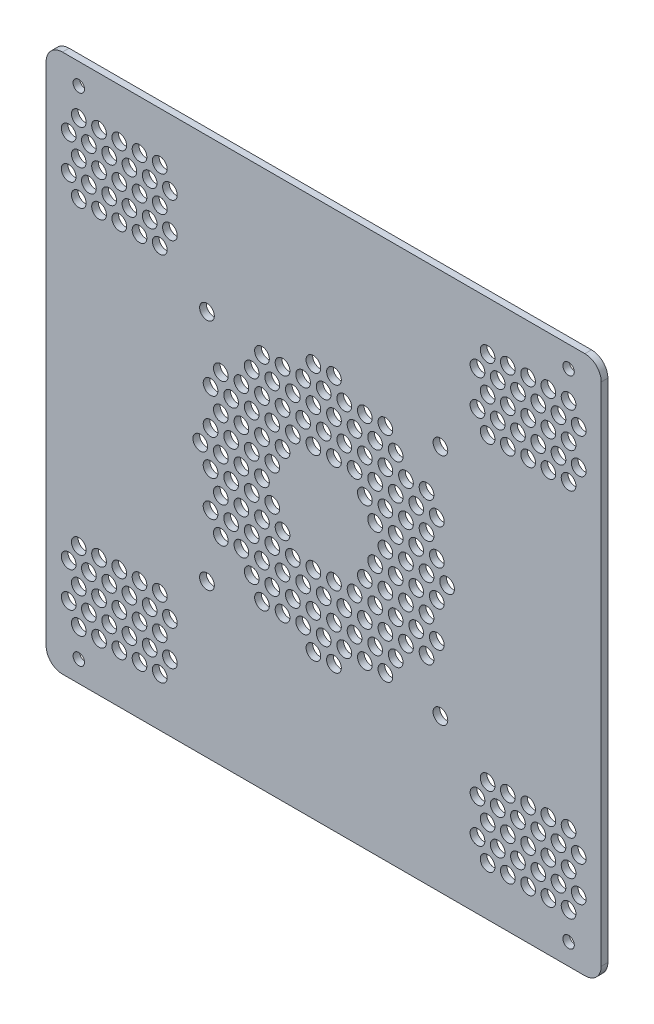
from build123d import *

# Parameters (mm, degrees)
SKETCH1_R            = 1.75
SKETCH1_R_2          = 2.25
BOSS_EXTRUDE1_DEPTH  = 2.032
SKETCH3_R            = 2.25
CUT_EXTRUDE2_DEPTH   = 3.032
LPATTERN1_COUNT      = 2
LPATTERN1_PITCH      = 113.5226
LPATTERN1_COUNT_DIR2 = 2
LPATTERN1_PITCH_DIR2 = 125.2
SKETCH4_R            = 2.25
CUT_EXTRUDE3_DEPTH   = 3.032
CIRPATTERN1_COUNT    = 6


with BuildPart() as part:
    # Sketch1 → Boss-Extrude1 (new body)
    with BuildSketch(Plane.XY):
        with BuildLine():
            Line((-80, 82.5), (80, 82.5))
            ThreePointArc((80, 82.5), (83.535533906, 81.035533906), (85, 77.5))
            Line((85, 77.5), (85, -77.5))
            ThreePointArc((85, -77.5), (83.535533906, -81.035533906), (80, -82.5))
            Line((80, -82.5), (-80, -82.5))
            ThreePointArc((-80, -82.5), (-83.535533906, -81.035533906), (-85, -77.5))
            Line((-85, -77.5), (-85, 77.5))
            ThreePointArc((-85, 77.5), (-83.535533906, 81.035533906), (-80, 82.5))
        make_face()
        with Locations((-75, 76)):
            Circle(SKETCH1_R, mode=Mode.SUBTRACT)
        with Locations((-75, -76)):
            Circle(SKETCH1_R, mode=Mode.SUBTRACT)
        with Locations((75, -76)):
            Circle(SKETCH1_R, mode=Mode.SUBTRACT)
        with Locations((75, 76)):
            Circle(SKETCH1_R, mode=Mode.SUBTRACT)
        with Locations((-35.75, 35.75)):
            Circle(SKETCH1_R_2, mode=Mode.SUBTRACT)
        with Locations((35.75, 35.75)):
            Circle(SKETCH1_R_2, mode=Mode.SUBTRACT)
        with Locations((35.75, -35.75)):
            Circle(SKETCH1_R_2, mode=Mode.SUBTRACT)
        with Locations((-35.75, -35.75)):
            Circle(SKETCH1_R_2, mode=Mode.SUBTRACT)
    extrude(amount=BOSS_EXTRUDE1_DEPTH)

    # Sketch3 → Cut-Extrude2 (cut, through all)
    with BuildSketch(Plane.XY.offset(2.032)):
        with Locations((47.1, 51.39192749)):
            Circle(SKETCH3_R)
        with Locations((53.3, 51.39192749)):
            Circle(SKETCH3_R)
        with Locations((59.5, 51.39192749)):
            Circle(SKETCH3_R)
        with Locations((65.7, 51.39192749)):
            Circle(SKETCH3_R)
        with Locations((71.9, 51.39192749)):
            Circle(SKETCH3_R)
        with Locations((78.1, 51.39192749)):
            Circle(SKETCH3_R)
        with Locations((75, 67.5)):
            Circle(SKETCH3_R)
        with Locations((68.8, 67.5)):
            Circle(SKETCH3_R)
        with Locations((62.6, 67.5)):
            Circle(SKETCH3_R)
        with Locations((56.4, 67.5)):
            Circle(SKETCH3_R)
        with Locations((50.2, 67.5)):
            Circle(SKETCH3_R)
        with Locations((53.3, 62.130642497)):
            Circle(SKETCH3_R)
        with Locations((75, 46.022569986)):
            Circle(SKETCH3_R)
        with Locations((68.8, 46.022569986)):
            Circle(SKETCH3_R)
        with Locations((62.6, 46.022569986)):
            Circle(SKETCH3_R)
        with Locations((56.4, 46.022569986)):
            Circle(SKETCH3_R)
        with Locations((50.2, 46.022569986)):
            Circle(SKETCH3_R)
        with Locations((59.5, 62.130642497)):
            Circle(SKETCH3_R)
        with Locations((65.7, 62.130642497)):
            Circle(SKETCH3_R)
        with Locations((71.9, 62.130642497)):
            Circle(SKETCH3_R)
        with Locations((50.2, 56.761284993)):
            Circle(SKETCH3_R)
        with Locations((56.4, 56.761284993)):
            Circle(SKETCH3_R)
        with Locations((62.6, 56.761284993)):
            Circle(SKETCH3_R)
        with Locations((68.8, 56.761284993)):
            Circle(SKETCH3_R)
        with Locations((75, 56.761284993)):
            Circle(SKETCH3_R)
        with Locations((78.1, 62.130642497)):
            Circle(SKETCH3_R)
        with Locations((47.1, 62.130642497)):
            Circle(SKETCH3_R)
    cut_extrude2 = extrude(amount=-CUT_EXTRUDE2_DEPTH, mode=Mode.SUBTRACT)

    # LPattern1: Cut-Extrude2 2 × 2
    with Locations(*[(-j * LPATTERN1_PITCH_DIR2, -i * LPATTERN1_PITCH, 0) for i in range(LPATTERN1_COUNT) for j in range(LPATTERN1_COUNT_DIR2) if (i, j) != (0, 0)]):
        add(cut_extrude2, mode=Mode.SUBTRACT)

    # Sketch4 → Cut-Extrude3 (cut, through all)
    with BuildSketch(Plane.XY.offset(2.032)):
        with Locations((-18.9, 0)):
            Circle(SKETCH4_R)
        with Locations((-34.65, 16.367880132)):
            Circle(SKETCH4_R)
        with Locations((-31.5, 21.823840175)):
            Circle(SKETCH4_R)
        with Locations((-25.2, 0)):
            Circle(SKETCH4_R)
        with Locations((-31.5, 0)):
            Circle(SKETCH4_R)
        with Locations((-37.8, 0)):
            Circle(SKETCH4_R)
        with Locations((-15.75, 5.455960044)):
            Circle(SKETCH4_R)
        with Locations((-22.05, 5.455960044)):
            Circle(SKETCH4_R)
        with Locations((-28.35, 5.455960044)):
            Circle(SKETCH4_R)
        with Locations((-34.65, 5.455960044)):
            Circle(SKETCH4_R)
        with Locations((-31.5, 10.911920088)):
            Circle(SKETCH4_R)
        with Locations((-25.2, 10.911920088)):
            Circle(SKETCH4_R)
        with Locations((-18.9, 10.911920088)):
            Circle(SKETCH4_R)
        with Locations((-12.6, 10.911920088)):
            Circle(SKETCH4_R)
        with Locations((-15.75, 16.367880132)):
            Circle(SKETCH4_R)
        with Locations((-22.05, 16.367880132)):
            Circle(SKETCH4_R)
        with Locations((-28.35, 16.367880132)):
            Circle(SKETCH4_R)
        with Locations((-18.9, 21.823840175)):
            Circle(SKETCH4_R)
        with Locations((-25.2, 21.823840175)):
            Circle(SKETCH4_R)
        with Locations((-22.05, 27.279800219)):
            Circle(SKETCH4_R)
    cut_extrude3 = extrude(amount=-CUT_EXTRUDE3_DEPTH, mode=Mode.SUBTRACT)

    # CirPattern1: Cut-Extrude3 ×6 about axis
    cirpattern1_axis = Axis((0, 0, 0), (0, 0, 1))
    for i in range(1, CIRPATTERN1_COUNT):
        add(cut_extrude3.rotate(cirpattern1_axis, i * 360 / CIRPATTERN1_COUNT), mode=Mode.SUBTRACT)


solid = part.part
